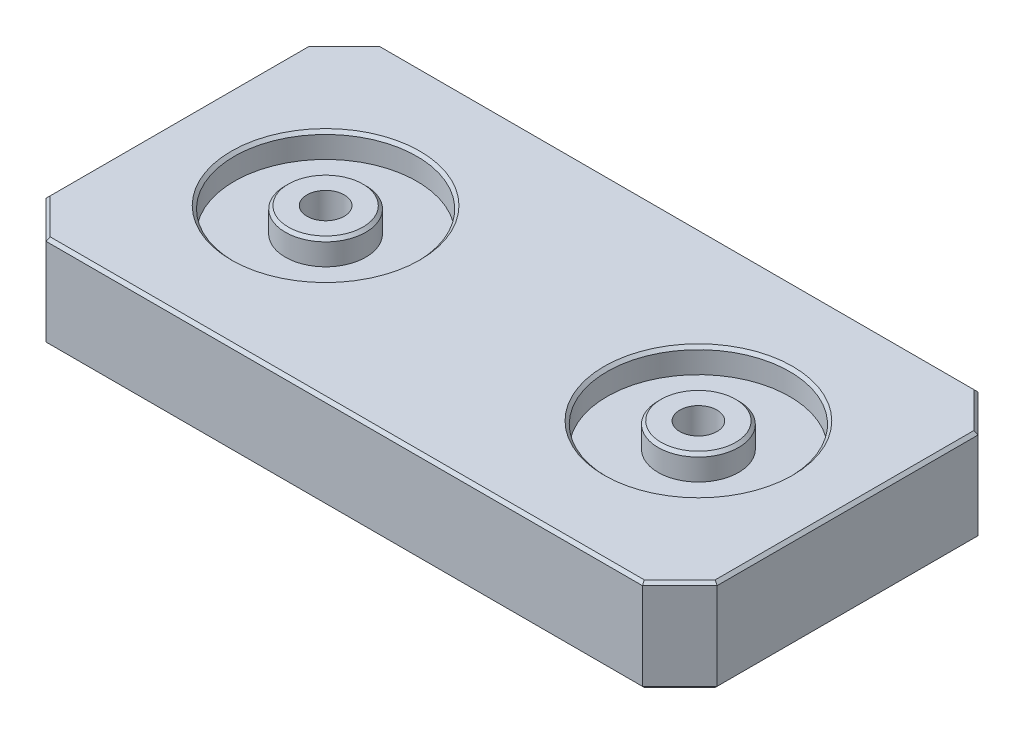
from build123d import *

# Parameters (mm, degrees)
SKETCH1_W               = 114.3
SKETCH1_H               = 57.15
EXTRUDE1_DEPTH          = 15.875
CUT_EXTRUDE1_DEPTH      = 16.875
SKETCH4_R               = 15.5575
EXTRUDE7_DEPTH          = 4.191
SKETCH6_R               = 6.858
EXTRUDE8_DEPTH          = 4.191
CHAMFER1_SIZE           = 0.508
SKETCH7_R               = 7.112
CUT_EXTRUDE2_DEPTH      = 1.905
F_1_4_20_TAPPED_HOLE1_D = 6.35


with BuildPart() as part:
    # Sketch1 → Extrude1 (new body)
    with BuildSketch(Plane(origin=(0, 0, 0), x_dir=(1, 0, 0), z_dir=(0, 1, 0))):
        Rectangle(SKETCH1_W, SKETCH1_H)
    extrude(amount=EXTRUDE1_DEPTH)

    # Sketch3 → Cut-Extrude1 (cut, through all)
    with BuildSketch(Plane(origin=(0, 15.875, 0), x_dir=(1, 0, 0), z_dir=(0, 1, 0))):
        Polygon((-57.15, 22.225), (-50.8, 28.575), (-57.15, 28.575), align=None)
        Polygon((-57.15, -28.575), (-57.15, -22.225), (-50.8, -28.575), align=None)
        Polygon((57.15, -28.575), (57.15, -22.225), (50.8, -28.575), align=None)
        Polygon((57.15, 28.575), (57.15, 22.225), (50.8, 28.575), align=None)
    extrude(amount=-CUT_EXTRUDE1_DEPTH, mode=Mode.SUBTRACT)

    # Sketch4 → Extrude7 (cut)
    with BuildSketch(Plane(origin=(0, 15.875, 0), x_dir=(1, 0, 0), z_dir=(0, 1, 0))):
        with Locations(Location((-31.75, 0, 0), (0, 0, 270))):  # turned: the seam where the file's is
            Circle(SKETCH4_R)
        with Locations(Location((31.75, 0, 0), (0, 0, 270))):  # turned: the seam where the file's is
            Circle(SKETCH4_R)
    extrude(amount=-EXTRUDE7_DEPTH, mode=Mode.SUBTRACT)

    # Sketch6 → Extrude8 (add)
    with BuildSketch(Plane(origin=(0, 11.684, 0), x_dir=(1, 0, 0), z_dir=(0, 1, 0))):
        with Locations(Location((-31.75, 0, 0), (0, 0, 270))):  # turned: the seam where the file's is
            Circle(SKETCH6_R)
        with Locations(Location((31.75, 0, 0), (0, 0, 270))):  # turned: the seam where the file's is
            Circle(SKETCH6_R)
    extrude(amount=EXTRUDE8_DEPTH)

    # Chamfer1
    chamfer1_edges = [part.edges().sort_by_distance(p)[0] for p in [
        (-57.15, 0, 0),
        (-57.15, 15.875, 0),
        (-53.975, 0, -25.4),
        (-53.975, 15.875, -25.4),
        (0, 0, 28.575),
        (0, 15.875, 28.575),
        (-53.975, 0, 25.4),
        (-53.975, 15.875, 25.4),
        (57.15, 0, 0),
        (57.15, 15.875, 0),
        (53.975, 0, 25.4),
        (53.975, 15.875, 25.4),
        (0, 0, -28.575),
        (0, 15.875, -28.575),
        (53.975, 0, -25.4),
        (53.975, 15.875, -25.4),
        (-31.75, 15.875, -15.5575),
        (31.75, 15.875, -15.5575),
        (-31.75, 15.875, -6.858),
        (31.75, 15.875, -6.858),
    ]]
    chamfer(chamfer1_edges, length=CHAMFER1_SIZE)

    # Sketch7 → Cut-Extrude2 (cut)
    with BuildSketch(Plane.XZ):
        with Locations(Location((-31.75, 15.875, 0), (0, 0, 270))):  # turned: the seam where the file's is
            Circle(SKETCH7_R)
        with Locations(Location((-31.75, -15.875, 0), (0, 0, 270))):  # turned: the seam where the file's is
            Circle(SKETCH7_R)
        with Locations(Location((31.75, 15.875, 0), (0, 0, 270))):  # turned: the seam where the file's is
            Circle(SKETCH7_R)
        with Locations(Location((31.75, -15.875, 0), (0, 0, 270))):  # turned: the seam where the file's is
            Circle(SKETCH7_R)
    extrude(amount=-CUT_EXTRUDE2_DEPTH, mode=Mode.SUBTRACT)

    # 1/4-20 Tapped Hole1 (through all)
    with Locations(Plane(origin=(0, 15.875, 0), x_dir=(-1, 0, 0), z_dir=(0, 1, 0))):
        with Locations((31.75, 0), (-31.75, 0)):
            Hole(F_1_4_20_TAPPED_HOLE1_D / 2)


solid = part.part
